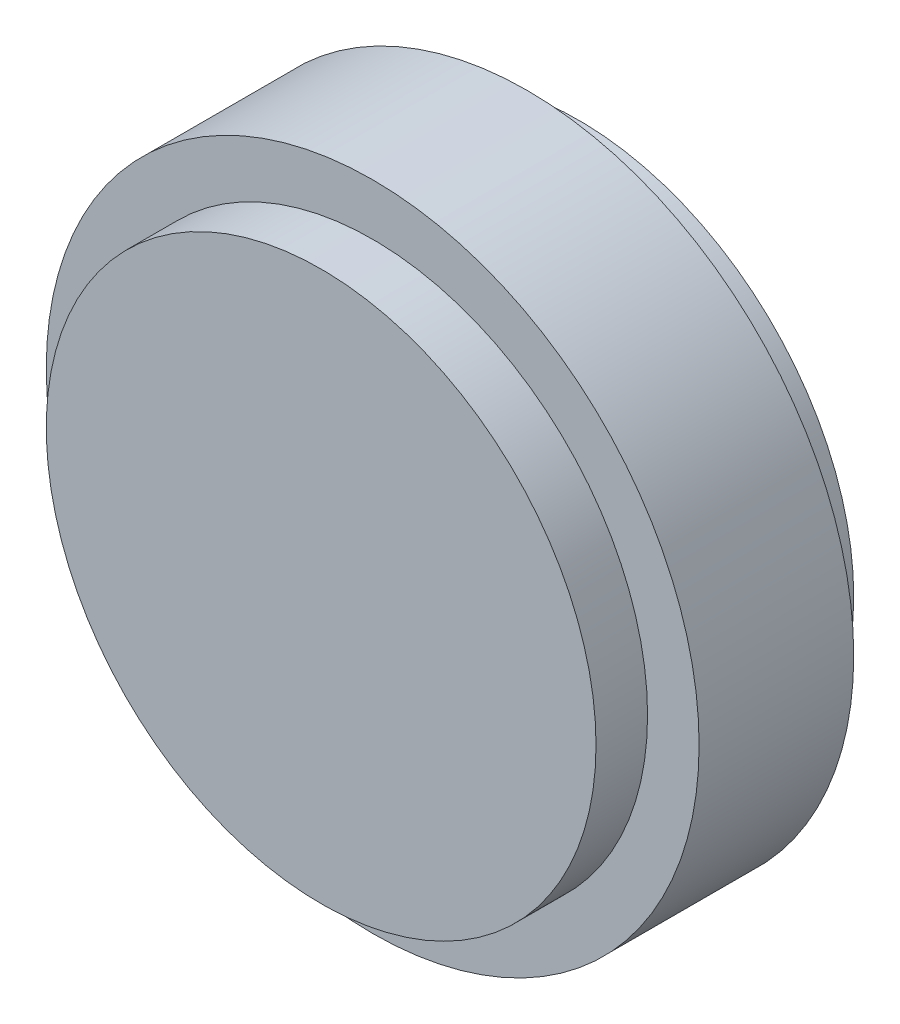
from build123d import *


with BuildPart() as part:
    # Sketch2 → Revolve1 (revolve)
    with BuildSketch(Plane(origin=(0, 0, 0), x_dir=(0, 0, -1), z_dir=(1, 0, 0))):
        Polygon((0, 0), (15, 0), (15, 16), (12, 16), (12, 19), (3, 19), (3, 16), (0, 16), align=None)
    revolve(axis=Axis((0, 0, 0), (0, 0, -1)))


solid = part.part
